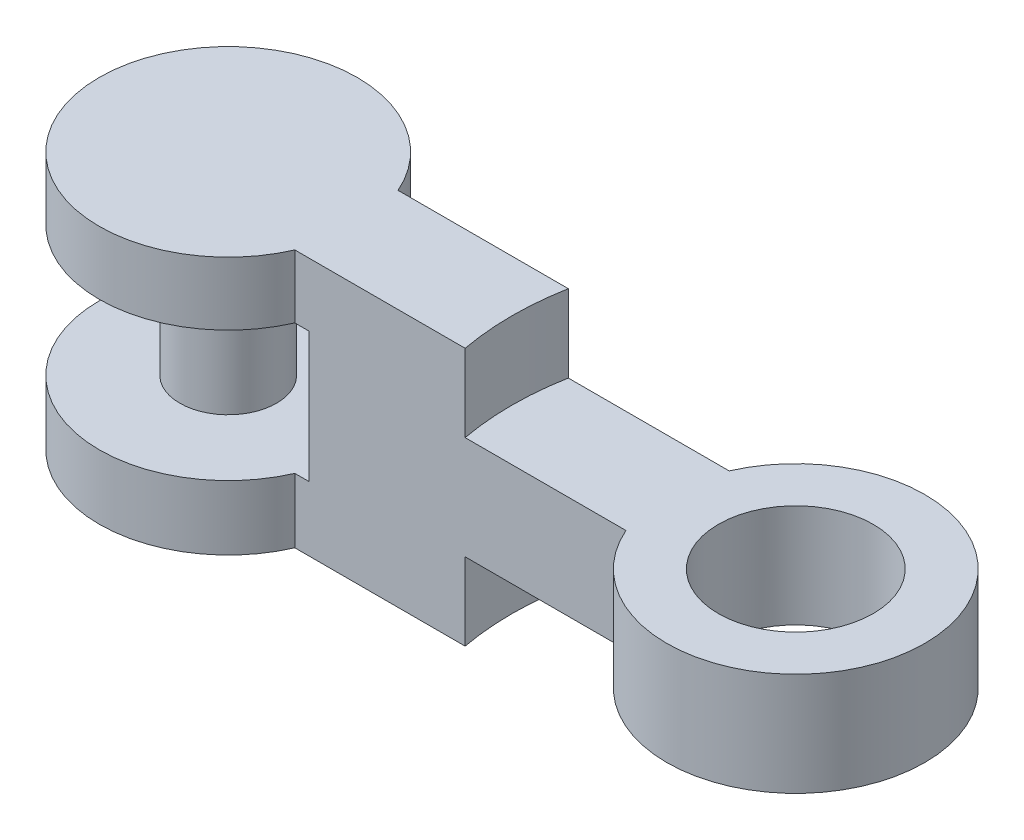
from build123d import *

# Parameters (mm, degrees)
SKETCH2_R               = 5
SKETCH2_R_2             = 1.875
SKETCH2_R_3             = 3
BOSS_EXTRUDE1_DEPTH     = 5
CUT_EXTRUDE1_START      = 2
SKETCH3_R               = 11
CUT_EXTRUDE1_DEPTH      = 4
SKETCH3_3_R             = 5.5
CUT_EXTRUDE2_DEPTH      = 2.55
CUT_EXTRUDE2_DEPTH_BACK = 2.5
SKETCH5_R               = 1.875
BOSS_EXTRUDE2_DEPTH     = 10


with BuildPart() as part:
    # Sketch2 → Boss-Extrude1 (new body, symmetric)
    with BuildSketch(Plane(origin=(0, 0, 0), x_dir=(1, 0, 0), z_dir=(0, 1, 0))):
        with Locations((-11, 0)):
            Circle(SKETCH2_R)
        with Locations((-11, 0)):
            Circle(SKETCH2_R_2, mode=Mode.SUBTRACT)
        with Locations((11, 0)):
            Circle(SKETCH2_R)
        with Locations((11, 0)):
            Circle(SKETCH2_R_3, mode=Mode.SUBTRACT)
        with BuildLine():
            ThreePointArc((-6, 0), (-6.105468435, -1.021548218), (-6.417424305, -2))
            Line((-6.417424305, -2), (6.417424305, -2))
            ThreePointArc((6.417424305, -2), (6, 0), (6.417424305, 2))
            Line((6.417424305, 2), (-6.417424305, 2))
            ThreePointArc((-6.417424305, 2), (-6.105468435, 1.021548218), (-6, 0))
        make_face()
    extrude(amount=BOSS_EXTRUDE1_DEPTH, both=True)

    # Sketch3 → Cut-Extrude1 (cut, through all)
    with BuildSketch(Plane(origin=(0, 0, 0), x_dir=(1, 0, 0), z_dir=(0, 1, 0)).offset(CUT_EXTRUDE1_START)):
        with Locations((11, 0)):
            Circle(SKETCH3_R)
    cut_extrude1 = extrude(amount=CUT_EXTRUDE1_DEPTH, mode=Mode.SUBTRACT)

    # Mirror2: Cut-Extrude1 across plane
    add(cut_extrude1.mirror(Plane.ZX), mode=Mode.SUBTRACT)

    # Sketch3_3 → Cut-Extrude2 (cut, two sides)
    with BuildSketch(Plane(origin=(0, 0, 0), x_dir=(1, 0, 0), z_dir=(0, 1, 0))) as cut_extrude2_sk:
        with Locations((-11, 0)):
            Circle(SKETCH3_3_R)
    extrude(amount=CUT_EXTRUDE2_DEPTH, mode=Mode.SUBTRACT)
    extrude(cut_extrude2_sk.sketch, amount=-CUT_EXTRUDE2_DEPTH_BACK, mode=Mode.SUBTRACT)

    # Sketch5 → Boss-Extrude2 (add)
    with BuildSketch(Plane(origin=(0, 5, 0), x_dir=(1, 0, 0), z_dir=(0, 1, 0))):
        with Locations((-11, 0)):
            Circle(SKETCH5_R)
    extrude(amount=-BOSS_EXTRUDE2_DEPTH)


solid = part.part
